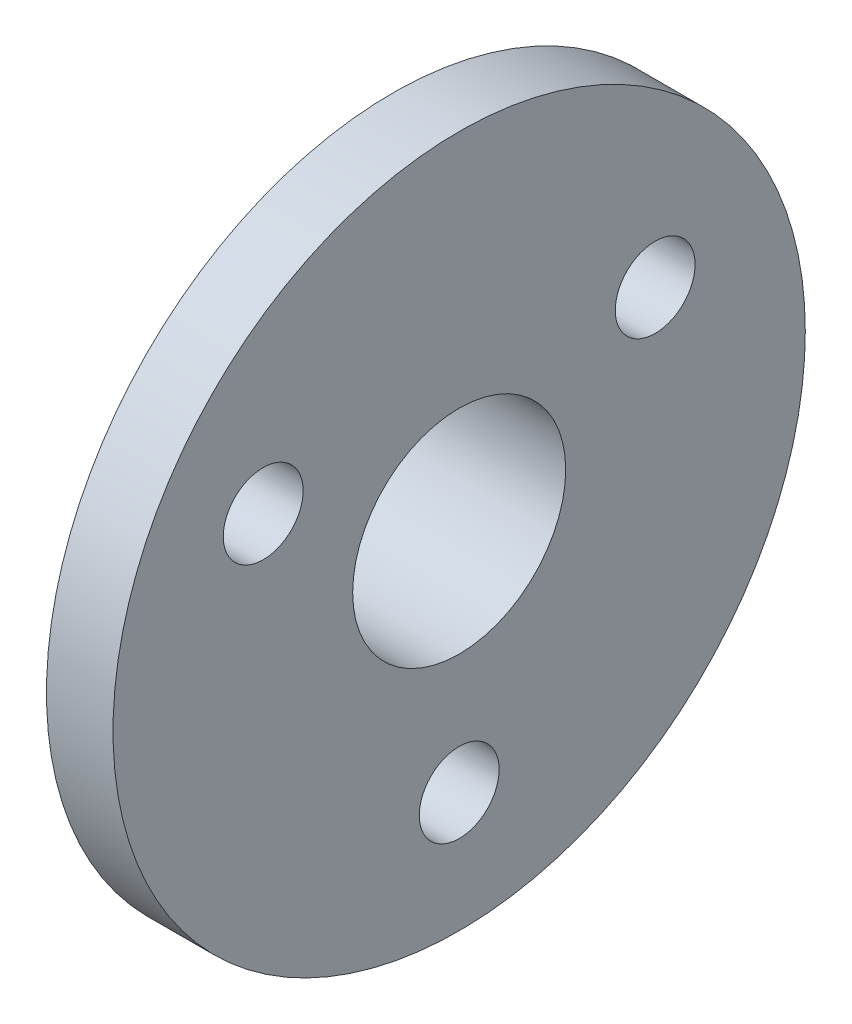
from build123d import *

# Parameters (mm, degrees)
SKETCH1_R           = 12.5
BOSS_EXTRUDE1_DEPTH = 7
SKETCH2_R           = 26
BOSS_EXTRUDE2_DEPTH = 5
SKETCH3_R           = 8
CUT_EXTRUDE1_DEPTH  = 13
SKETCH4_R           = 3
CUT_EXTRUDE3_DEPTH  = 13
CIRPATTERN2_COUNT   = 3


with BuildPart() as part:
    # Sketch1 → Boss-Extrude1 (new body)
    with BuildSketch(Plane(origin=(0, 0, 0), x_dir=(0, 0, -1), z_dir=(1, 0, 0))):
        Circle(SKETCH1_R)
    extrude(amount=BOSS_EXTRUDE1_DEPTH)

    # Sketch2 → Boss-Extrude2 (add)
    with BuildSketch(Plane(origin=(7, 0, 0), x_dir=(0, 0, -1), z_dir=(1, 0, 0))):
        Circle(SKETCH2_R)
    extrude(amount=BOSS_EXTRUDE2_DEPTH)

    # Sketch3 → Cut-Extrude1 (cut, through all)
    with BuildSketch(Plane(origin=(12, 0, 0), x_dir=(0, 0, -1), z_dir=(1, 0, 0))):
        Circle(SKETCH3_R)
    extrude(amount=-CUT_EXTRUDE1_DEPTH, mode=Mode.SUBTRACT)

    # Sketch4 → Cut-Extrude3 (cut, through all)
    with BuildSketch(Plane(origin=(12, 0, 0), x_dir=(0, 0, -1), z_dir=(1, 0, 0))):
        with Locations((0, -17)):
            Circle(SKETCH4_R)
    cut_extrude3 = extrude(amount=-CUT_EXTRUDE3_DEPTH, mode=Mode.SUBTRACT)

    # CirPattern2: Cut-Extrude3 ×3 about axis
    cirpattern2_axis = Axis((0, 0, 0), (1, 0, 0))
    for i in range(1, CIRPATTERN2_COUNT):
        add(cut_extrude3.rotate(cirpattern2_axis, i * 360 / CIRPATTERN2_COUNT), mode=Mode.SUBTRACT)


solid = part.part
